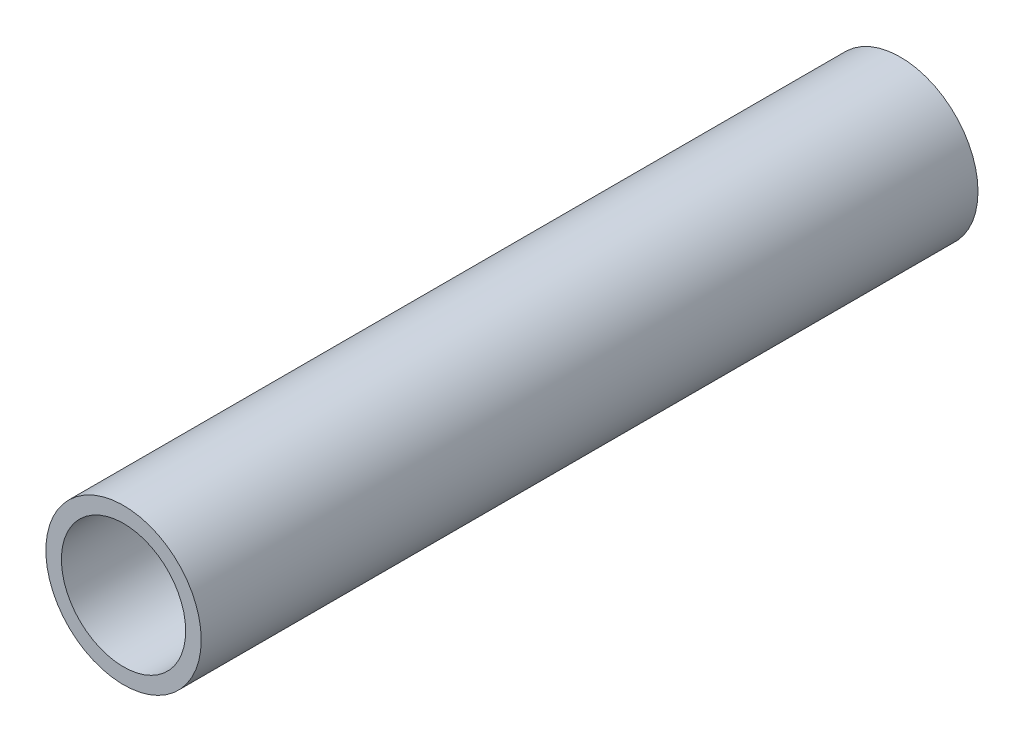
from build123d import *

# Parameters (mm, degrees)
SKETCH1_R           = 12.7
SKETCH1_R_2         = 10.16
BOSS_EXTRUDE1_DEPTH = 127


with BuildPart() as part:
    # Sketch1 → Boss-Extrude1 (new body)
    with BuildSketch(Plane.XY):
        Circle(SKETCH1_R)
        Circle(SKETCH1_R_2, mode=Mode.SUBTRACT)
    extrude(amount=BOSS_EXTRUDE1_DEPTH)


solid = part.part
